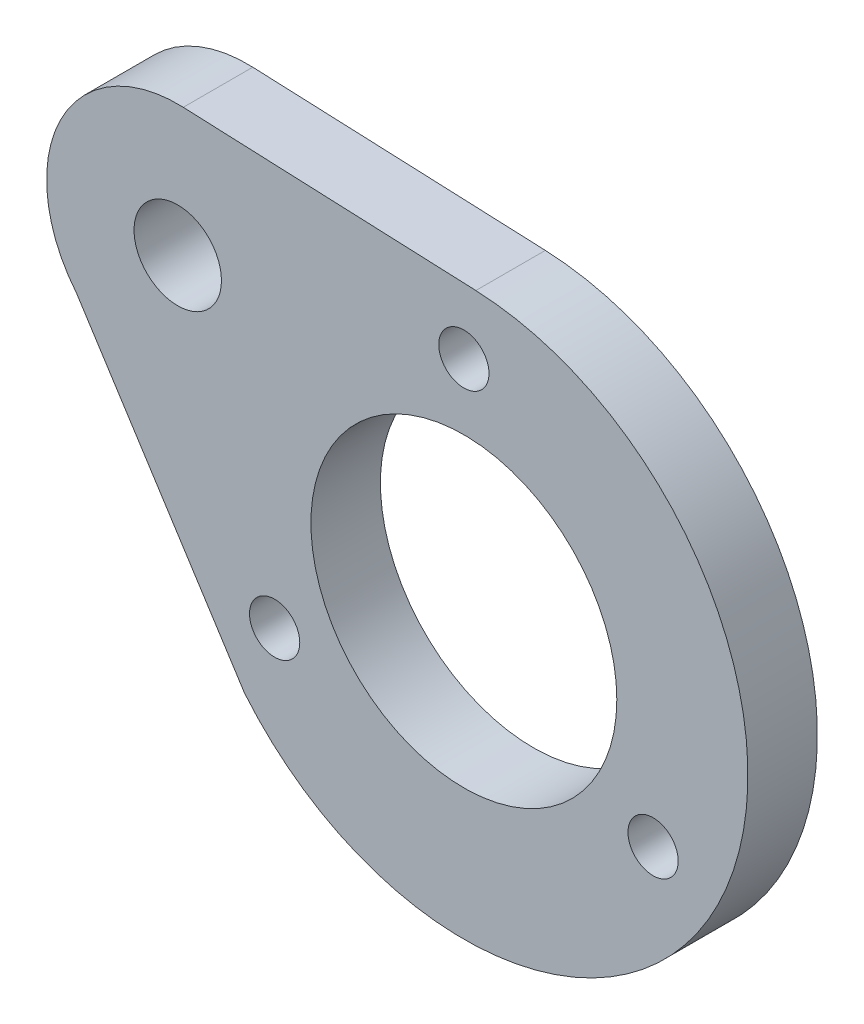
from build123d import *

# Parameters (mm, degrees)
SKETCH1_R           = 3.5
SKETCH1_R_2         = 0.575
SKETCH1_R_3         = 1
BOSS_EXTRUDE1_DEPTH = 1.59


with BuildPart() as part:
    # Sketch1 → Boss-Extrude1 (new body)
    with BuildSketch(Plane.XY):
        with BuildLine():
            Line((38.934590504, 57.571868893), (45.629621497, 57.288743472))
            ThreePointArc((45.629621497, 57.288743472), (51.171586425, 47.893307318), (40.332417108, 46.668560697))
            Line((40.332417108, 46.668560697), (36.48972694, 52.670246074))
            ThreePointArc((36.48972694, 52.670246074), (36.123253783, 55.913581906), (38.934590504, 57.571868893))
        make_face()
        with Locations((45.35498918, 50.794547826)):
            Circle(SKETCH1_R, mode=Mode.SUBTRACT)
        with Locations((45.35498918, 55.794547826)):
            Circle(SKETCH1_R_2, mode=Mode.SUBTRACT)
        with Locations((49.685116199, 48.294547826)):
            Circle(SKETCH1_R_2, mode=Mode.SUBTRACT)
        with Locations((41.024862161, 48.294547826)):
            Circle(SKETCH1_R_2, mode=Mode.SUBTRACT)
        with Locations((38.807837127, 54.574547826)):
            Circle(SKETCH1_R_3, mode=Mode.SUBTRACT)
    extrude(amount=BOSS_EXTRUDE1_DEPTH)


solid = part.part
